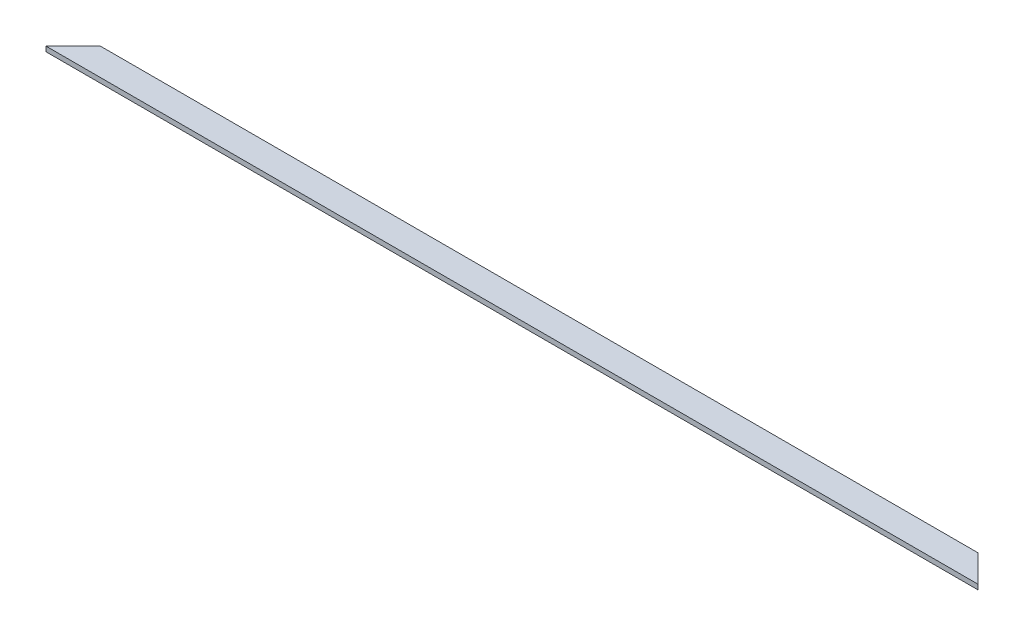
from build123d import *

# Parameters (mm, degrees)
BOSS_EXTRUDE1_DEPTH = 25.4


with BuildPart() as part:
    # Sketch1 → Boss-Extrude1 (new body)
    with BuildSketch(Plane(origin=(0, 0, 0), x_dir=(1, 0, 0), z_dir=(0, 1, 0))):
        Polygon((4787.9, 0), (4648.2, 139.7), (139.7, 139.7), (0, 0), align=None)
    extrude(amount=BOSS_EXTRUDE1_DEPTH)


solid = part.part
